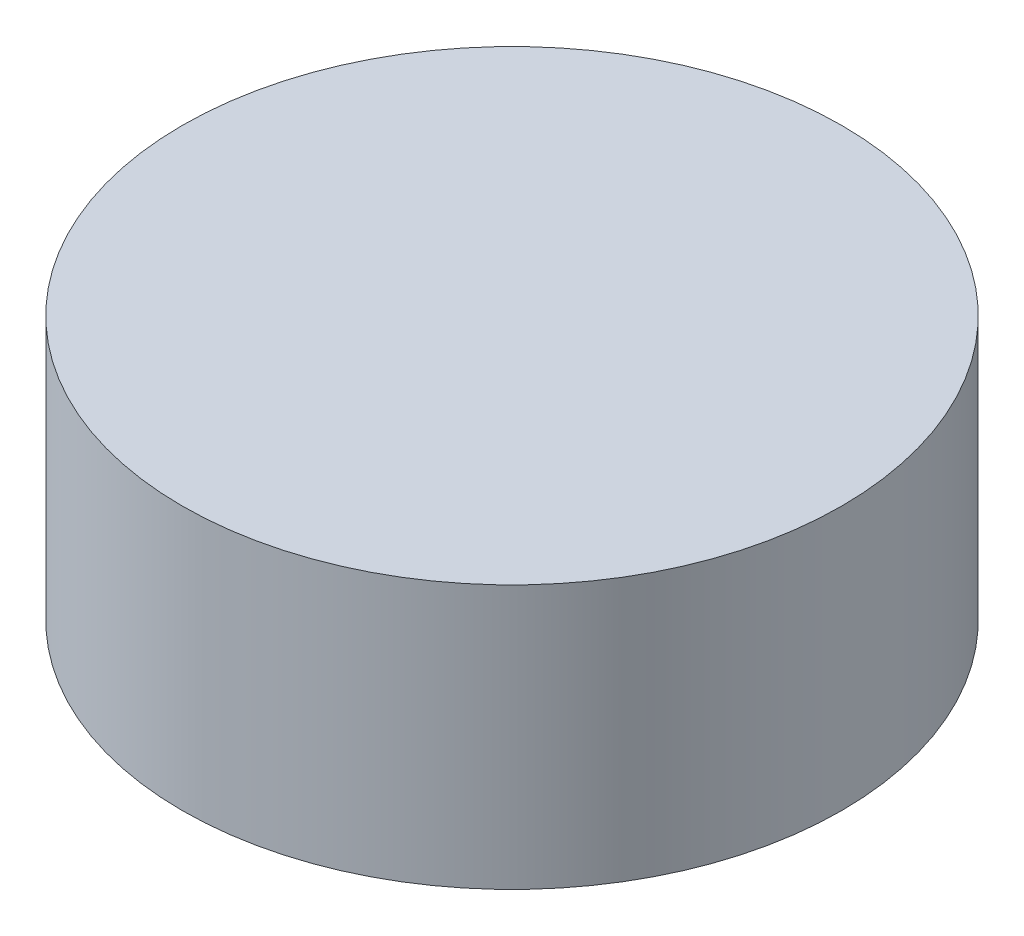
from build123d import *

# Parameters (mm, degrees)
SKETCH1_R           = 25
BOSS_EXTRUDE1_DEPTH = 20


with BuildPart() as part:
    # Sketch1 → Boss-Extrude1 (new body)
    with BuildSketch(Plane(origin=(0, 0, 0), x_dir=(1, 0, 0), z_dir=(0, 1, 0))):
        Circle(SKETCH1_R)
    extrude(amount=BOSS_EXTRUDE1_DEPTH)


solid = part.part
